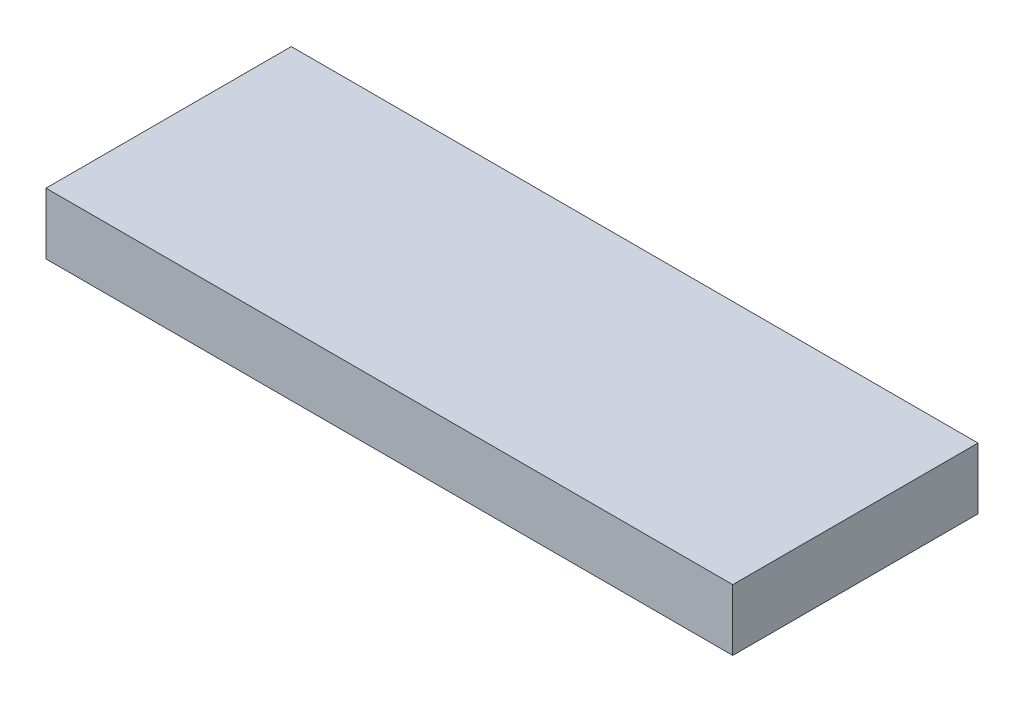
from build123d import *

# Parameters (mm, degrees)
SKETCH1_W           = 35.56
SKETCH1_H           = 12.7
BOSS_EXTRUDE1_DEPTH = 3.175


with BuildPart() as part:
    # Sketch1 → Boss-Extrude1 (new body)
    with BuildSketch(Plane(origin=(0, 0, 0), x_dir=(1, 0, 0), z_dir=(0, 1, 0))):
        Rectangle(SKETCH1_W, SKETCH1_H)
    extrude(amount=BOSS_EXTRUDE1_DEPTH)


solid = part.part
